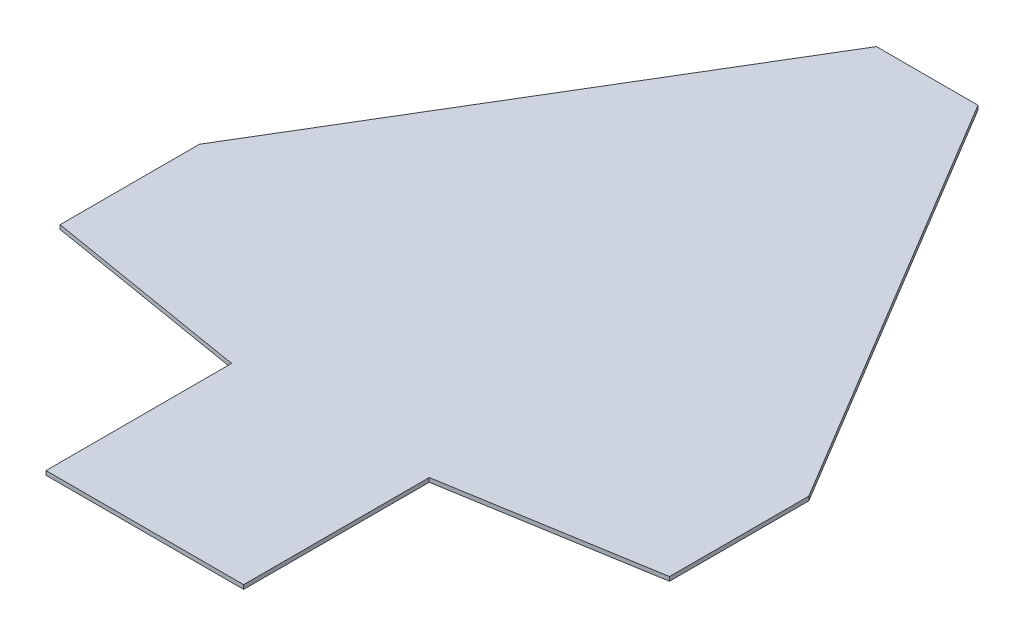
from build123d import *

# Parameters (mm, degrees)
BOSS_EXTRUDE1_DEPTH = 2.54


with BuildPart() as part:
    # Sketch1 → Boss-Extrude1 (new body)
    with BuildSketch(Plane(origin=(0, 0, 0), x_dir=(1, 0, 0), z_dir=(0, 1, 0))):
        Polygon((54.753993456, 82.213636442), (-7.920052482, 82.213636442), (-164.543029513, -178.766701674), (-164.543029513, -264.696747554), (-37.543029513, -285.910409438), (-37.543029513, -400.386363558), (84.376970487, -400.386363558), (84.376970487, -285.910409438), (211.376970487, -264.696747554), (211.376970487, -178.766701674), align=None)
    extrude(amount=BOSS_EXTRUDE1_DEPTH)


solid = part.part
